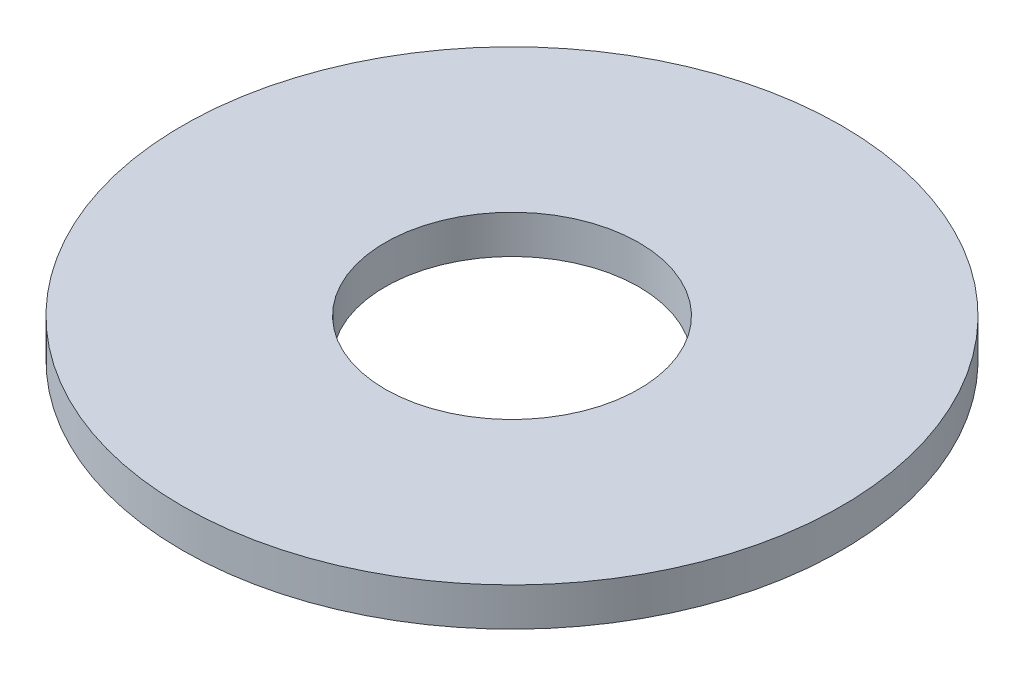
from build123d import *

# Parameters (mm, degrees)
SKETCH1_R           = 8.7376
SKETCH1_R_2         = 3.3655
BOSS_EXTRUDE1_DEPTH = 1.016


with BuildPart() as part:
    # Sketch1 → Boss-Extrude1 (new body)
    with BuildSketch(Plane(origin=(0, 0, 0), x_dir=(1, 0, 0), z_dir=(0, 1, 0))):
        Circle(SKETCH1_R)
        Circle(SKETCH1_R_2, mode=Mode.SUBTRACT)
    extrude(amount=BOSS_EXTRUDE1_DEPTH)


solid = part.part
